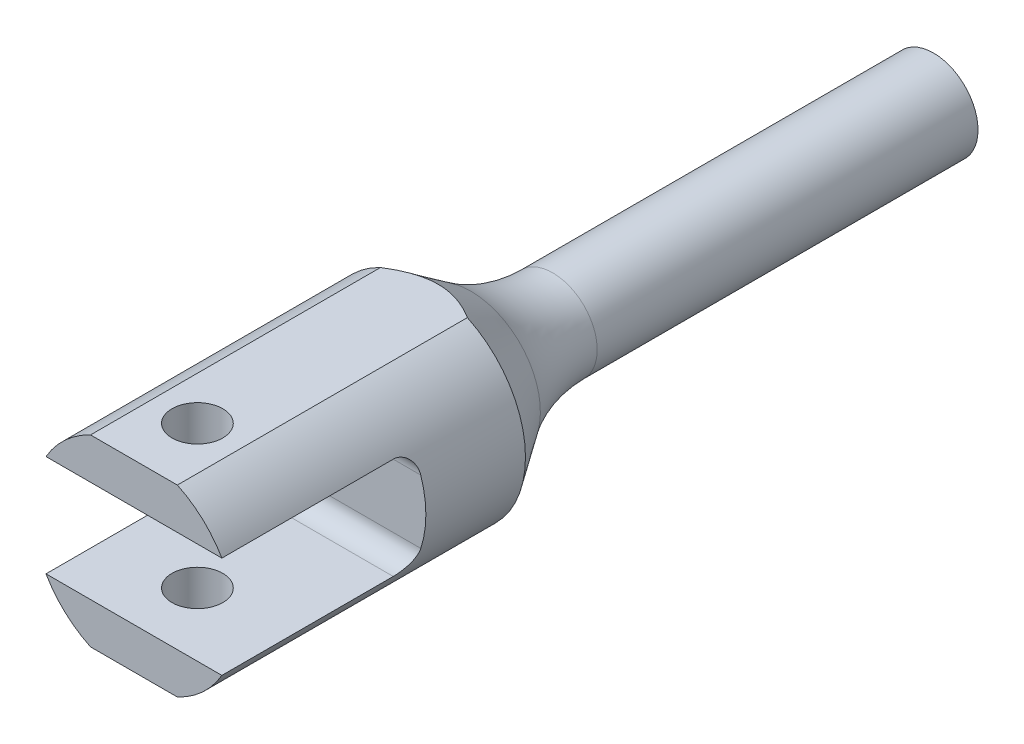
from build123d import *

# Parameters (mm, degrees)
SKETCH1_R               = 16
BOSS_EXTRUDE1_DEPTH     = 146
SKETCH2_W               = 150.836885197
SKETCH2_H               = 19.135619971
CUT_EXTRUDE2_DEPTH      = 17
CUT_EXTRUDE2_DEPTH_BACK = 17
SKETCH3_R               = 4
CUT_EXTRUDE3_DEPTH      = 15.463502114
CUT_EXTRUDE3_DEPTH_BACK = 15.463502114
SKETCH5_W               = 20
SKETCH5_H               = 24.196648242
CUT_EXTRUDE4_DEPTH      = 17.0000001
CUT_EXTRUDE4_DEPTH_BACK = 17.0000001
SKETCH6_R               = 4
CUT_EXTRUDE5_DEPTH      = 29


with BuildPart() as part:
    # Sketch1 → Boss-Extrude1 (new body)
    with BuildSketch(Plane.XY):
        Circle(SKETCH1_R)
    extrude(amount=BOSS_EXTRUDE1_DEPTH)

    # Sketch2 → Cut-Extrude2 (cut, two sides)
    with BuildSketch(Plane(origin=(0, 0, 0), x_dir=(0, 0, -1), z_dir=(1, 0, 0))) as cut_extrude2_sk:
        with BuildLine():
            Line((-116, -5), (-116, 5))
            ThreePointArc((-116, 5), (-116.878679656, 7.121320344), (-119, 8))
            Line((-119, 8), (-146, 8))
            Line((-146, 8), (-146, -8))
            Line((-146, -8), (-119, -8))
            ThreePointArc((-119, -8), (-116.878679656, -7.121320344), (-116, -5))
        make_face()
        with Locations((-70.581557402, -24.031312)):
            Rectangle(SKETCH2_W, SKETCH2_H)
        with Locations((-70.581557402, 24.031312)):
            Rectangle(SKETCH2_W, SKETCH2_H)
    extrude(amount=CUT_EXTRUDE2_DEPTH, mode=Mode.SUBTRACT)
    extrude(cut_extrude2_sk.sketch, amount=-CUT_EXTRUDE2_DEPTH_BACK, mode=Mode.SUBTRACT)

    # Sketch3 → Cut-Extrude3 (cut, two sides)
    with BuildSketch(Plane(origin=(0, 0, 0), x_dir=(1, 0, 0), z_dir=(0, 1, 0))) as cut_extrude3_sk:
        with Locations((0, -136)):
            Circle(SKETCH3_R)
    extrude(amount=CUT_EXTRUDE3_DEPTH, mode=Mode.SUBTRACT)
    extrude(cut_extrude3_sk.sketch, amount=-CUT_EXTRUDE3_DEPTH_BACK, mode=Mode.SUBTRACT)

    # Sketch4 → Cut-Revolve3 (revolve, cut)
    with BuildSketch(Plane(origin=(0, 0, 0), x_dir=(0, 0, -1), z_dir=(1, 0, 0))):
        with BuildLine():
            Line((0, 7), (-80, 7))
            ThreePointArc((-80, 7), (-86.772424654, 8.019684618), (-92.944350416, 10.988324842))
            Line((-92.944350416, 10.988324842), (-118.219798108, 28.197447612))
            Line((-118.219798108, 28.197447612), (0, 28.197447612))
            Line((0, 28.197447612), (0, 7))
        make_face()
    revolve(axis=Axis((0, 0, 0), (0, 0, 1)), mode=Mode.SUBTRACT)

    # Sketch5 → Cut-Extrude4 (cut, two sides)
    with BuildSketch(Plane(origin=(0, 0, 0), x_dir=(0, 0, -1), z_dir=(1, 0, 0))) as cut_extrude4_sk:
        with Locations((-10, 0)):
            Rectangle(SKETCH5_W, SKETCH5_H)
    extrude(amount=CUT_EXTRUDE4_DEPTH, mode=Mode.SUBTRACT)
    extrude(cut_extrude4_sk.sketch, amount=-CUT_EXTRUDE4_DEPTH_BACK, mode=Mode.SUBTRACT)

    # Sketch6 → Cut-Extrude5 (cut)
    with BuildSketch(Plane(origin=(0, 0, 20), x_dir=(-1, 0, 0), z_dir=(0, 0, -1))):
        Circle(SKETCH6_R)
    extrude(amount=-CUT_EXTRUDE5_DEPTH, mode=Mode.SUBTRACT)


solid = part.part
